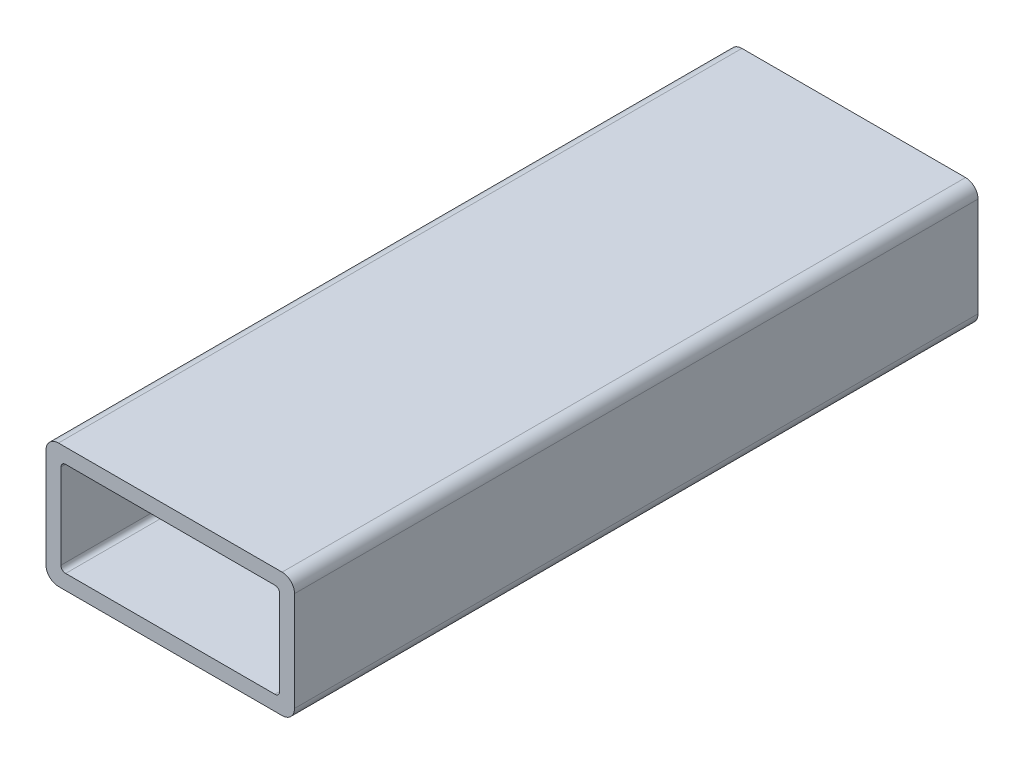
from build123d import *

# Parameters (mm, degrees)
BOSS_EXTRUDE1_DEPTH = 139.7


with BuildPart() as part:
    # Sketch4 → Boss-Extrude1 (new body)
    with BuildSketch(Plane.XY):
        with BuildLine():
            Line((25.4, -10.16), (25.4, 10.16))
            ThreePointArc((25.4, 10.16), (24.656051224, 11.956051224), (22.86, 12.7))
            Line((22.86, 12.7), (-22.86, 12.7))
            ThreePointArc((-22.86, 12.7), (-24.656051224, 11.956051224), (-25.4, 10.16))
            Line((-25.4, 10.16), (-25.4, -10.16))
            ThreePointArc((-25.4, -10.16), (-24.656051224, -11.956051224), (-22.86, -12.7))
            Line((-22.86, -12.7), (22.86, -12.7))
            ThreePointArc((22.86, -12.7), (24.656051224, -11.956051224), (25.4, -10.16))
        make_face()
        with BuildLine():
            Line((22.352, 8.6868), (22.352, -8.6868))
            ThreePointArc((22.352, -8.6868), (22.069299465, -9.369299465), (21.3868, -9.652))
            Line((21.3868, -9.652), (-21.3868, -9.652))
            ThreePointArc((-21.3868, -9.652), (-22.069299465, -9.369299465), (-22.352, -8.6868))
            Line((-22.352, -8.6868), (-22.352, 8.6868))
            ThreePointArc((-22.352, 8.6868), (-22.069299465, 9.369299465), (-21.3868, 9.652))
            Line((-21.3868, 9.652), (21.3868, 9.652))
            ThreePointArc((21.3868, 9.652), (22.069299465, 9.369299465), (22.352, 8.6868))
        make_face(mode=Mode.SUBTRACT)
    extrude(amount=BOSS_EXTRUDE1_DEPTH)


solid = part.part
